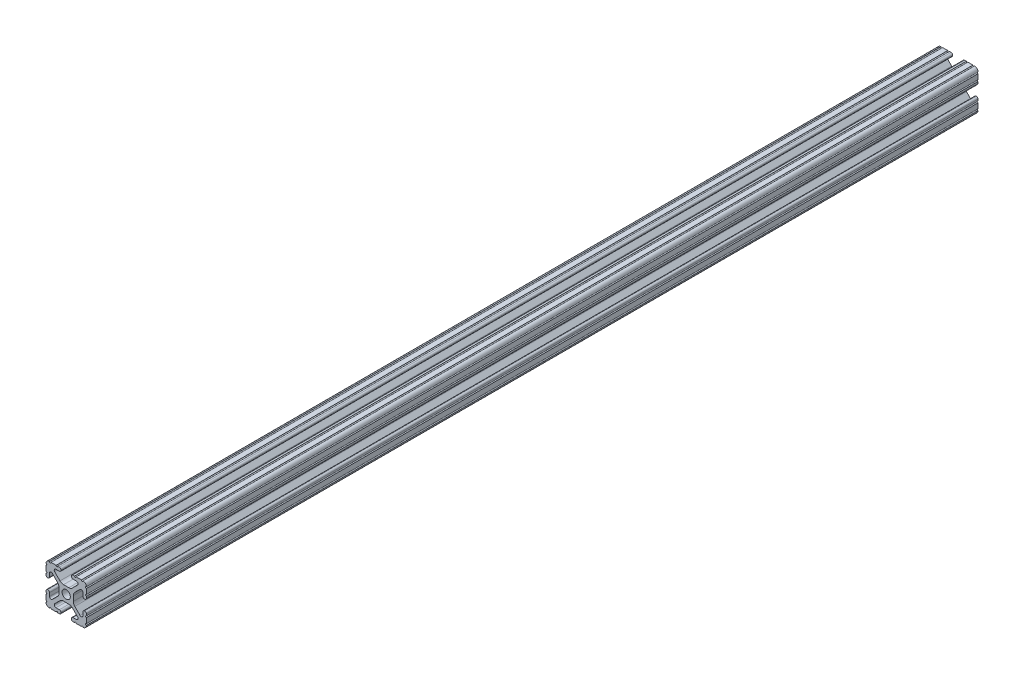
from build123d import *

# Parameters (mm, degrees)
SKETCH1_R           = 2.6035
BOSS_EXTRUDE1_DEPTH = 304.8
SKETCH2_W           = 33.638821573
SKETCH2_H           = 37.212624088
CUT_EXTRUDE1_DEPTH  = 48.26


with BuildPart() as part:
    # Sketch1 → Boss-Extrude1 (new body, symmetric)
    with BuildSketch(Plane.XY):
        with BuildLine():
            Line((-7.179650497, -8.645192506), (-3.952270251, -5.423690499))
            ThreePointArc((-3.952270251, -5.423690499), (-2.922936451, -4.736929036), (-1.709253557, -4.4958))
            Line((-1.709253557, -4.4958), (1.709253557, -4.4958))
            ThreePointArc((1.709253557, -4.4958), (2.922936451, -4.736929036), (3.952270251, -5.423690499))
            Line((3.952270251, -5.423690499), (7.179650497, -8.645192506))
            ThreePointArc((7.179650497, -8.645192506), (7.41473083, -9.822813117), (6.416408329, -10.4902))
            Line((6.416408329, -10.4902), (4.287512407, -10.4902))
            ThreePointArc((4.287512407, -10.4902), (3.54574862, -10.79744862), (3.2385, -11.539212407))
            Line((3.2385, -11.539212407), (3.2385, -11.650987593))
            ThreePointArc((3.2385, -11.650987593), (3.54574862, -12.39275138), (4.287512407, -12.7))
            Line((4.287512407, -12.7), (5.317126718, -12.7))
            ThreePointArc((5.317126718, -12.7), (5.825126718, -12.192), (6.333126718, -12.7))
            Line((6.333126718, -12.7), (9.550443118, -12.7))
            ThreePointArc((9.550443118, -12.7), (10.058366869, -12.192000006), (10.566443095, -12.699847501))
            ThreePointArc((10.566443095, -12.699847501), (12.082537762, -12.08250727), (12.699846982, -10.566399977))
            ThreePointArc((12.699846982, -10.566399977), (12.192000006, -10.058323491), (12.7, -9.5504))
            Line((12.7, -9.5504), (12.7, -6.3330836))
            ThreePointArc((12.7, -6.3330836), (12.192, -5.8250836), (12.7, -5.3170836))
            Line((12.7, -5.3170836), (12.7, -4.287469289))
            ThreePointArc((12.7, -4.287469289), (12.39275138, -3.545705502), (11.650987593, -3.238456882))
            Line((11.650987593, -3.238456882), (11.539212407, -3.238456882))
            ThreePointArc((11.539212407, -3.238456882), (10.79744862, -3.545705502), (10.4902, -4.287469289))
            Line((10.4902, -4.287469289), (10.4902, -6.402089023))
            ThreePointArc((10.4902, -6.402089023), (9.856505071, -7.351067942), (8.737131347, -7.129408934))
            Line((8.737131347, -7.129408934), (5.441005833, -3.840816462))
            ThreePointArc((5.441005833, -3.840816462), (4.750877967, -2.809883091), (4.5085, -1.593185507))
            Line((4.5085, -1.593185507), (4.5085, 1.593185507))
            ThreePointArc((4.5085, 1.593185507), (4.750877967, 2.809883091), (5.441005833, 3.840816462))
            Line((5.441005833, 3.840816462), (8.737131347, 7.129408934))
            ThreePointArc((8.737131347, 7.129408934), (9.856505071, 7.351067942), (10.4902, 6.402089023))
            Line((10.4902, 6.402089023), (10.4902, 4.287469289))
            ThreePointArc((10.4902, 4.287469289), (10.79744862, 3.545705502), (11.539212407, 3.238456882))
            Line((11.539212407, 3.238456882), (11.650987593, 3.238456882))
            ThreePointArc((11.650987593, 3.238456882), (12.39275138, 3.545705502), (12.7, 4.287469289))
            Line((12.7, 4.287469289), (12.7, 5.3170836))
            ThreePointArc((12.7, 5.3170836), (12.192, 5.8250836), (12.7, 6.3330836))
            Line((12.7, 6.3330836), (12.7, 9.5504))
            ThreePointArc((12.7, 9.5504), (12.192000006, 10.058323491), (12.699846982, 10.566399977))
            ThreePointArc((12.699846982, 10.566399977), (12.082537762, 12.08250727), (10.566443095, 12.699847501))
            ThreePointArc((10.566443095, 12.699847501), (10.058366869, 12.192000006), (9.550443118, 12.7))
            Line((9.550443118, 12.7), (6.333126718, 12.7))
            ThreePointArc((6.333126718, 12.7), (5.825126718, 12.192), (5.317126718, 12.7))
            Line((5.317126718, 12.7), (4.287512407, 12.7))
            ThreePointArc((4.287512407, 12.7), (3.54574862, 12.39275138), (3.2385, 11.650987593))
            Line((3.2385, 11.650987593), (3.2385, 11.539212407))
            ThreePointArc((3.2385, 11.539212407), (3.54574862, 10.79744862), (4.287512407, 10.4902))
            Line((4.287512407, 10.4902), (6.476788598, 10.4902))
            ThreePointArc((6.476788598, 10.4902), (7.432222385, 9.85140422), (7.207036008, 8.724370562))
            Line((7.207036008, 8.724370562), (3.898272566, 5.423169045))
            ThreePointArc((3.898272566, 5.423169045), (2.869120213, 4.736787962), (1.655778399, 4.4958))
            Line((1.655778399, 4.4958), (-1.655778399, 4.4958))
            ThreePointArc((-1.655778399, 4.4958), (-2.869120213, 4.736787962), (-3.898272566, 5.423169045))
            Line((-3.898272566, 5.423169045), (-7.207036008, 8.724370562))
            ThreePointArc((-7.207036008, 8.724370562), (-7.432222385, 9.85140422), (-6.476788598, 10.4902))
            Line((-6.476788598, 10.4902), (-4.287512407, 10.4902))
            ThreePointArc((-4.287512407, 10.4902), (-3.54574862, 10.79744862), (-3.2385, 11.539212407))
            Line((-3.2385, 11.539212407), (-3.2385, 11.650987593))
            ThreePointArc((-3.2385, 11.650987593), (-3.54574862, 12.39275138), (-4.287512407, 12.7))
            Line((-4.287512407, 12.7), (-5.317126718, 12.7))
            ThreePointArc((-5.317126718, 12.7), (-5.825126718, 12.192), (-6.333126718, 12.7))
            Line((-6.333126718, 12.7), (-9.550443118, 12.7))
            ThreePointArc((-9.550443118, 12.7), (-10.058366869, 12.192000006), (-10.566443095, 12.699847501))
            ThreePointArc((-10.566443095, 12.699847501), (-12.082537762, 12.08250727), (-12.699846982, 10.566399977))
            ThreePointArc((-12.699846982, 10.566399977), (-12.192000006, 10.058323491), (-12.7, 9.5504))
            Line((-12.7, 9.5504), (-12.7, 6.3330836))
            ThreePointArc((-12.7, 6.3330836), (-12.192, 5.8250836), (-12.7, 5.3170836))
            Line((-12.7, 5.3170836), (-12.7, 4.287469289))
            ThreePointArc((-12.7, 4.287469289), (-12.39275138, 3.545705502), (-11.650987593, 3.238456882))
            Line((-11.650987593, 3.238456882), (-11.539212407, 3.238456882))
            ThreePointArc((-11.539212407, 3.238456882), (-10.79744862, 3.545705502), (-10.4902, 4.287469289))
            Line((-10.4902, 4.287469289), (-10.4902, 6.402089023))
            ThreePointArc((-10.4902, 6.402089023), (-9.856505071, 7.351067942), (-8.737131347, 7.129408934))
            Line((-8.737131347, 7.129408934), (-5.441005833, 3.840816462))
            ThreePointArc((-5.441005833, 3.840816462), (-4.750877967, 2.809883091), (-4.5085, 1.593185507))
            Line((-4.5085, 1.593185507), (-4.5085, -1.593185507))
            ThreePointArc((-4.5085, -1.593185507), (-4.750877967, -2.809883091), (-5.441005833, -3.840816462))
            Line((-5.441005833, -3.840816462), (-8.737131347, -7.129408934))
            ThreePointArc((-8.737131347, -7.129408934), (-9.856505071, -7.351067942), (-10.4902, -6.402089023))
            Line((-10.4902, -6.402089023), (-10.4902, -4.287469289))
            ThreePointArc((-10.4902, -4.287469289), (-10.79744862, -3.545705502), (-11.539212407, -3.238456882))
            Line((-11.539212407, -3.238456882), (-11.650987593, -3.238456882))
            ThreePointArc((-11.650987593, -3.238456882), (-12.39275138, -3.545705502), (-12.7, -4.287469289))
            Line((-12.7, -4.287469289), (-12.7, -5.3170836))
            ThreePointArc((-12.7, -5.3170836), (-12.192, -5.8250836), (-12.7, -6.3330836))
            Line((-12.7, -6.3330836), (-12.7, -9.5504))
            ThreePointArc((-12.7, -9.5504), (-12.192000006, -10.058323491), (-12.699846982, -10.566399977))
            ThreePointArc((-12.699846982, -10.566399977), (-12.082537762, -12.08250727), (-10.566443095, -12.699847501))
            ThreePointArc((-10.566443095, -12.699847501), (-10.058366869, -12.192000006), (-9.550443118, -12.7))
            Line((-9.550443118, -12.7), (-6.333126718, -12.7))
            ThreePointArc((-6.333126718, -12.7), (-5.825126718, -12.192), (-5.317126718, -12.7))
            Line((-5.317126718, -12.7), (-4.287512407, -12.7))
            ThreePointArc((-4.287512407, -12.7), (-3.54574862, -12.39275138), (-3.2385, -11.650987593))
            Line((-3.2385, -11.650987593), (-3.2385, -11.539212407))
            ThreePointArc((-3.2385, -11.539212407), (-3.54574862, -10.79744862), (-4.287512407, -10.4902))
            Line((-4.287512407, -10.4902), (-6.416408329, -10.4902))
            ThreePointArc((-6.416408329, -10.4902), (-7.41473083, -9.822813117), (-7.179650497, -8.645192506))
        make_face()
        Circle(SKETCH1_R, mode=Mode.SUBTRACT)
    extrude(amount=BOSS_EXTRUDE1_DEPTH, both=True)

    # Sketch2 → Cut-Extrude1 (cut)
    with BuildSketch(Plane.XY.offset(304.8)):
        with Locations((1.09831089, -1.115775642)):
            Rectangle(SKETCH2_W, SKETCH2_H)
    extrude(amount=-CUT_EXTRUDE1_DEPTH, mode=Mode.SUBTRACT)


solid = part.part
